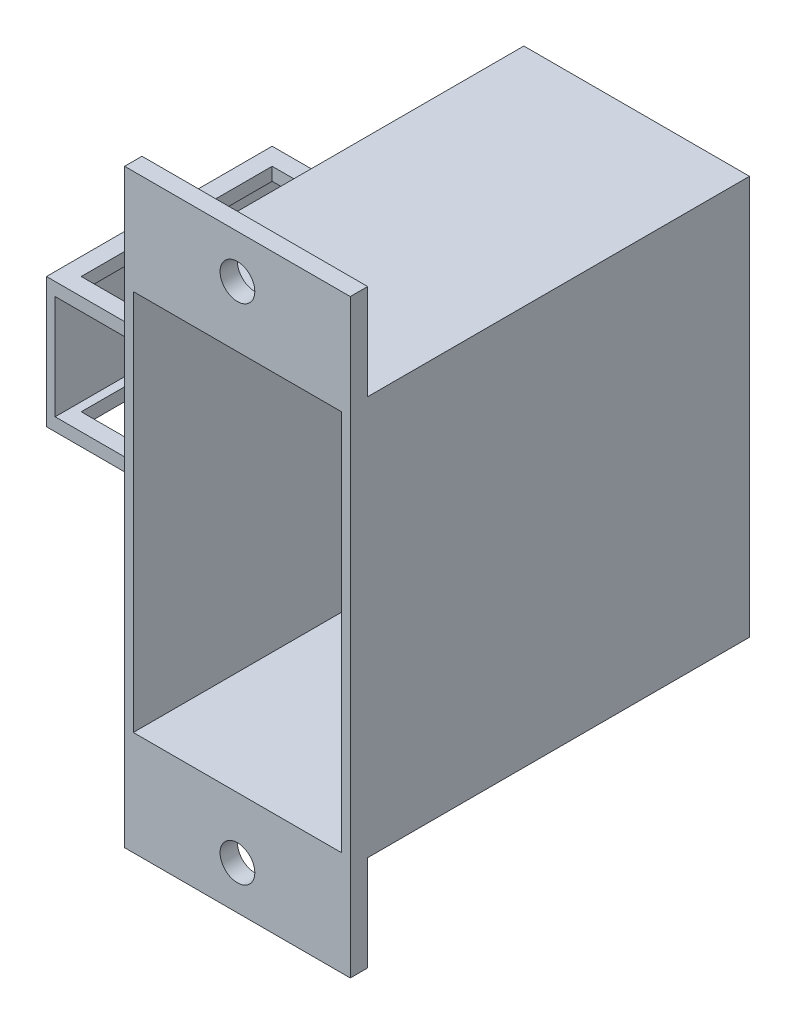
from build123d import *

# Parameters (mm, degrees)
SKETCH1_W           = 13
SKETCH1_H           = 23
BOSS_EXTRUDE1_DEPTH = 23
CUT_EXTRUDE1_REACH  = 28.524
SKETCH1_3_W         = 12
SKETCH1_3_H         = 22
SKETCH2_W           = 13
SKETCH2_H           = 5.5
SKETCH2_R           = 1
BOSS_EXTRUDE2_DEPTH = 1
SKETCH4_W           = 13
SKETCH4_H           = 7.5
BOSS_EXTRUDE3_DEPTH = 10
CUT_EXTRUDE2_REACH  = 37.097
SKETCH5_W           = 8
SKETCH5_H           = 11
CUT_EXTRUDE3_REACH  = 31.453
SKETCH6_W           = 9
SKETCH6_H           = 6


with BuildPart() as part:
    # Sketch1 → Boss-Extrude1 (new body)
    with BuildSketch(Plane.XY):
        Rectangle(SKETCH1_W, SKETCH1_H)
    extrude(amount=BOSS_EXTRUDE1_DEPTH)

    # Sketch1_3 → Cut-Extrude1 (cut, up to next)
    with BuildSketch(Plane.XY, mode=Mode.PRIVATE) as cut_extrude1_sk1:
        Rectangle(SKETCH1_3_W, SKETCH1_3_H)
    cut_extrude1_tool1 = extrude(cut_extrude1_sk1.sketch, amount=CUT_EXTRUDE1_REACH, mode=Mode.PRIVATE) & part.part
    add(cut_extrude1_tool1.solids().sort_by_distance((0, 0, 0))[0], mode=Mode.SUBTRACT)

    # Sketch2 → Boss-Extrude2 (add)
    # profile 1 of 2: a face of its own
    with BuildSketch(Plane.XY.offset(23)):
        with Locations((0, 14.25)):
            Rectangle(SKETCH2_W, SKETCH2_H)
        with Locations((0, 14.5)):
            Circle(SKETCH2_R, mode=Mode.SUBTRACT)
    # profile 2 of 2: a face of its own
    with BuildSketch(Plane.XY.offset(23)):
        with Locations((0, -14.25)):
            Rectangle(SKETCH2_W, SKETCH2_H)
        with Locations((0, -14.5)):
            Circle(SKETCH2_R, mode=Mode.SUBTRACT)
    extrude(amount=-BOSS_EXTRUDE2_DEPTH)

    # Sketch4 → Boss-Extrude3 (add)
    with BuildSketch(Plane.ZY.offset(6.5)):
        with Locations((11, 0)):
            Rectangle(SKETCH4_W, SKETCH4_H)
    extrude(amount=BOSS_EXTRUDE3_DEPTH)

    # Sketch5 → Cut-Extrude2 (cut, up to next)
    with BuildSketch(Plane(origin=(0, -3.75, 0), x_dir=(-1, 0, 0), z_dir=(0, -1, 0)), mode=Mode.PRIVATE) as cut_extrude2_sk1:
        with Locations((11.5, -11)):
            Rectangle(SKETCH5_W, SKETCH5_H)
    cut_extrude2_tool1 = extrude(cut_extrude2_sk1.sketch, amount=-CUT_EXTRUDE2_REACH, mode=Mode.PRIVATE) & part.part
    add(cut_extrude2_tool1.solids().sort_by_distance((-11.5, -3.75, 11))[0], mode=Mode.SUBTRACT)

    # Sketch6 → Cut-Extrude3 (cut, up to next)
    with BuildSketch(Plane.XY.offset(17.5), mode=Mode.PRIVATE) as cut_extrude3_sk1:
        with Locations((-11.5, 0)):
            Rectangle(SKETCH6_W, SKETCH6_H)
    cut_extrude3_tool1 = extrude(cut_extrude3_sk1.sketch, amount=-CUT_EXTRUDE3_REACH, mode=Mode.PRIVATE) & part.part
    add(cut_extrude3_tool1.solids().sort_by_distance((-11.5, 0, 17.5))[0], mode=Mode.SUBTRACT)


solid = part.part
